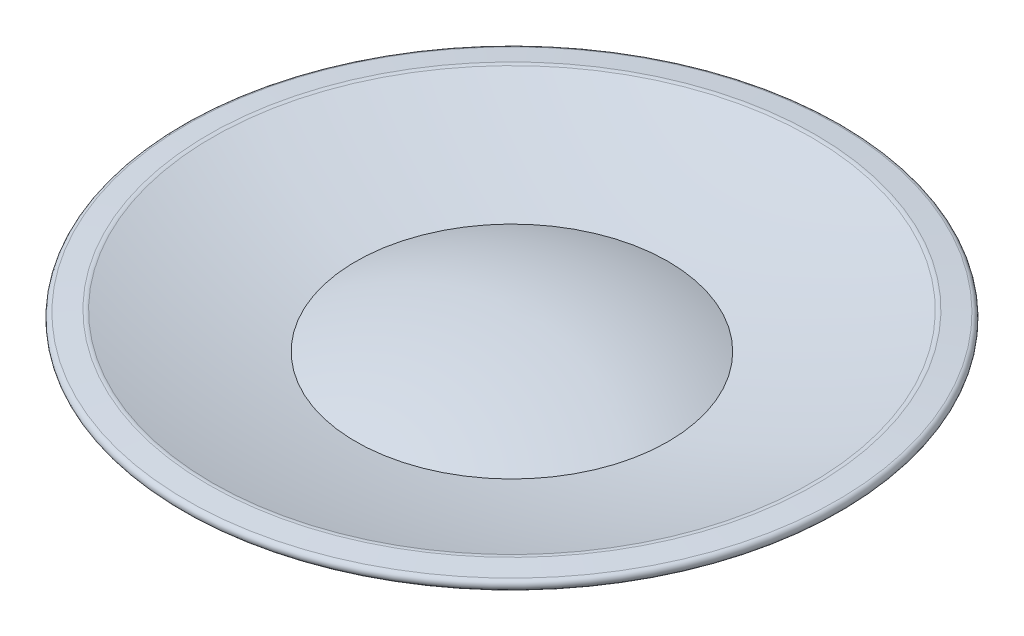
from build123d import *


with BuildPart() as part:
    # Sketch1 → Revolve1 (revolve)
    with BuildSketch(Plane.XY, mode=Mode.PRIVATE) as revolve1_sk:
        with BuildLine():
            Line((-1.5, 0), (-1.5, 1.25))
            ThreePointArc((-1.5, 1.25), (-2.884297868, 1.519499587), (-4.239486894, 1.909849842))
            ThreePointArc((-4.239486894, 1.909849842), (-4.281710291, 1.975667162), (-4.226641621, 2.031184515))
            Line((-4.226641621, 2.031184515), (-3.941677503, 2.063693004))
            ThreePointArc((-3.941677503, 2.063693004), (-3.915470962, 2.063917474), (-3.889793603, 2.058672821))
            ThreePointArc((-3.889793603, 2.058672821), (-2.966307435, 1.797086773), (-2.028602191, 1.592238444))
            ThreePointArc((-2.028602191, 1.592238444), (-1.034588848, 1.897050215), (0, 2))
            Line((0, 2), (0, 1))
            Line((0, 1), (-1.4375, 1))
            Line((-1.4375, 1), (-1.4375, 0))
            Line((-1.4375, 0), (-1.5, 0))
        make_face()
    revolve(revolve1_sk.sketch.rotate(Axis((0, 0, 0), (0, 1, 0)), 270), axis=Axis((0, 0, 0), (0, 1, 0)))  # turned: the seam where the file's is


solid = part.part
